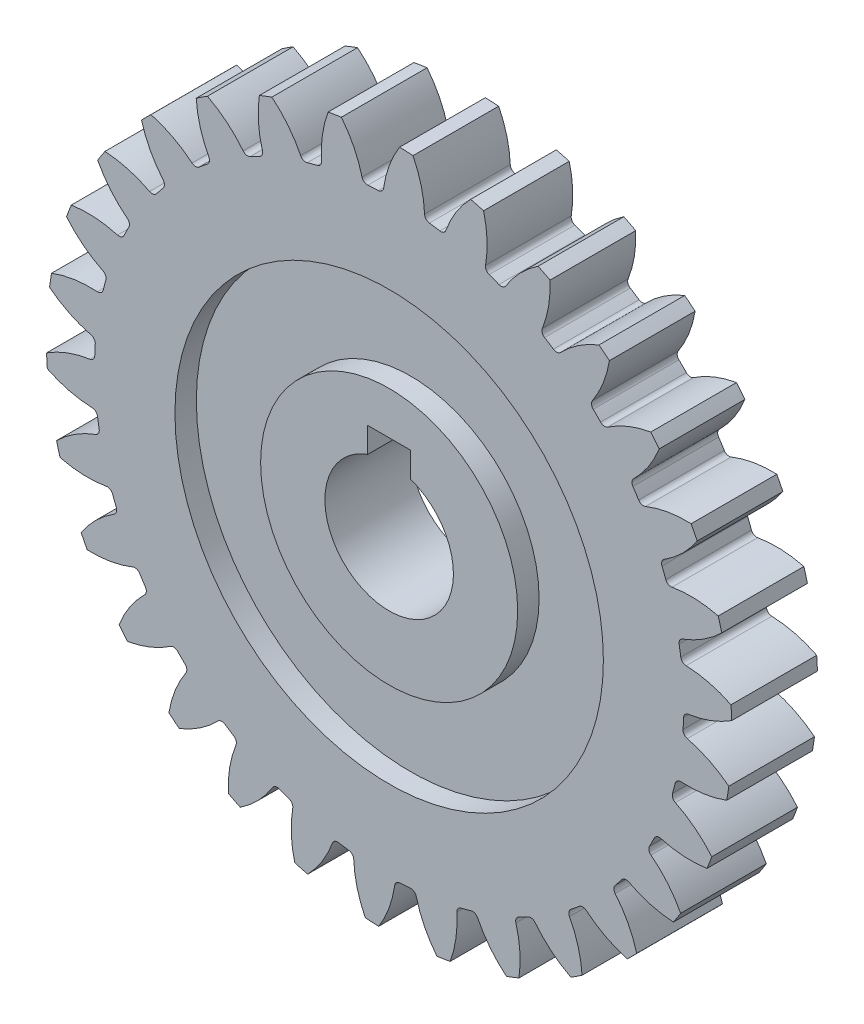
from build123d import *

# Parameters (mm, degrees)
SKETCH1_R           = 80
BOSS_EXTRUDE2_DEPTH = 10
CUT_EXTRUDE1_DEPTH  = 20
SKETCH3_R           = 50
CUT_EXTRUDE2_DEPTH  = 5
SKETCH4_R           = 15
CUT_EXTRUDE3_DEPTH  = 16
SKETCH5_R           = 30
SKETCH5_R_2         = 15
BOSS_EXTRUDE3_DEPTH = 5
SKETCH6_W           = 10
SKETCH6_H           = 10
CUT_EXTRUDE4_DEPTH  = 21


with BuildPart() as part:
    # Sketch1 → Boss-Extrude2 (new body, symmetric)
    with BuildSketch(Plane.XY):
        Circle(SKETCH1_R)
    extrude(amount=BOSS_EXTRUDE2_DEPTH, both=True)

    # Sketch2 → Cut-Extrude1 (cut)
    with BuildSketch(Plane.XY.offset(10)):
        with BuildLine():
            ThreePointArc((19.012601921, 77.707920885), (12.331914738, 79.043809871), (5.561789996, 79.806431395))
            ThreePointArc((5.561789996, 79.806431395), (7.470498978, 74.717944098), (8.264356437, 69.34154537))
            ThreePointArc((8.264356437, 69.34154537), (8.600794132, 68.520294229), (9.385815062, 68.106306431))
            ThreePointArc((9.385815062, 68.106306431), (10.597739228, 67.928274108), (11.806299123, 67.728677833))
            ThreePointArc((11.806299123, 67.728677833), (12.680118941, 67.883863802), (13.250731596, 68.56360269))
            ThreePointArc((13.250731596, 68.56360269), (15.64458276, 73.442675302), (19.012601921, 77.707920885))
        make_face()
        with BuildLine():
            ThreePointArc((-4.979384841, 68.569440909), (-3.756929125, 68.647272222), (-2.533280764, 68.703311336))
            ThreePointArc((-2.533280764, 68.703311336), (-1.710820983, 69.036783475), (-1.294003245, 69.820305479))
            ThreePointArc((-1.294003245, 69.820305479), (0.033120291, 75.090468292), (2.440745731, 79.962758583))
            ThreePointArc((2.440745731, 79.962758583), (-4.371699345, 79.880462222), (-11.152438549, 79.218830554))
            ThreePointArc((-11.152438549, 79.218830554), (-8.22748344, 74.638381825), (-6.333157521, 69.544522555))
            ThreePointArc((-6.333157521, 69.544522555), (-5.833324084, 68.811167052), (-4.979384841, 68.569440909))
        make_face()
        with BuildLine():
            ThreePointArc((-15.782183935, 68.025525884), (-15.579789694, 73.456447493), (-14.237782758, 78.722840028))
            ThreePointArc((-14.237782758, 78.722840028), (-20.884249189, 77.225955066), (-27.379252014, 75.168986684))
            ThreePointArc((-27.379252014, 75.168986684), (-23.565885352, 71.296764112), (-20.653882106, 66.708070393))
            ThreePointArc((-20.653882106, 66.708070393), (-20.012498046, 66.094661683), (-19.126961734, 66.035761787))
            ThreePointArc((-19.126961734, 66.035761787), (-17.947401647, 66.366055134), (-16.762144126, 66.675280459))
            ThreePointArc((-16.762144126, 66.675280459), (-16.026989821, 67.172464435), (-15.782183935, 68.025525884))
        make_face()
        with BuildLine():
            ThreePointArc((-29.580607456, 63.257704386), (-30.511788109, 68.612027456), (-30.294051821, 74.04235561))
            ThreePointArc((-30.294051821, 74.04235561), (-36.484057131, 71.196303101), (-42.409460786, 67.833897395))
            ThreePointArc((-42.409460786, 67.833897395), (-37.874344993, 64.839135687), (-34.071932934, 60.956155454))
            ThreePointArc((-34.071932934, 60.956155454), (-33.317029813, 60.48950244), (-32.438598617, 60.616003001))
            ThreePointArc((-32.438598617, 60.616003001), (-31.353486597, 61.184322978), (-30.258421356, 61.733219882))
            ThreePointArc((-30.258421356, 61.733219882), (-29.642702297, 62.37238637), (-29.580607456, 63.257704386))
        make_face()
        with BuildLine():
            ThreePointArc((-42.086216488, 55.725217661), (-44.110274972, 60.768932582), (-45.026325452, 66.125864957))
            ThreePointArc((-45.026325452, 66.125864957), (-50.489336705, 62.055031054), (-55.586172618, 57.534141287))
            ThreePointArc((-55.586172618, 57.534141287), (-50.527514016, 55.5477259), (-46.000876798, 52.540164022))
            ThreePointArc((-46.000876798, 52.540164022), (-45.165447504, 52.24066168), (-44.332513083, 52.547034015))
            ThreePointArc((-44.332513083, 52.547034015), (-43.389273731, 53.328542312), (-42.432260377, 54.093121368))
            ThreePointArc((-42.432260377, 54.093121368), (-41.962886442, 54.846335725), (-42.086216488, 55.725217661))
        make_face()
        with BuildLine():
            ThreePointArc((-52.752455906, 45.757271526), (-55.780931154, 50.269943752), (-57.790732601, 55.319356698))
            ThreePointArc((-57.790732601, 55.319356698), (-62.287989991, 50.201656376), (-66.333501975, 44.719867125))
            ThreePointArc((-66.333501975, 44.719867125), (-60.972388218, 43.828613943), (-55.919361609, 41.827915306))
            ThreePointArc((-55.919361609, 41.827915306), (-55.039918411, 41.708653326), (-54.288883996, 42.181507494))
            ThreePointArc((-54.288883996, 42.181507494), (-53.528741398, 43.142048448), (-52.751606006, 44.088893882))
            ThreePointArc((-52.751606006, 44.088893882), (-52.449091089, 44.923237027), (-52.752455906, 45.757271526))
        make_face()
        with BuildLine():
            ThreePointArc((-61.113159868, 33.789513057), (-65.013692977, 37.573917159), (-68.029407424, 42.095127099))
            ThreePointArc((-68.029407424, 42.095127099), (-71.364359223, 36.154228421), (-74.181738993, 29.95112018))
            ThreePointArc((-74.181738993, 29.95112018), (-68.752476478, 30.193981244), (-63.393901987, 29.287585978))
            ThreePointArc((-63.393901987, 29.287585978), (-62.508880773, 29.353776681), (-61.872570171, 29.972446687))
            ThreePointArc((-61.872570171, 29.972446687), (-61.328746207, 31.070040049), (-60.765453323, 32.157770172))
            ThreePointArc((-60.765453323, 32.157770172), (-60.643018776, 33.036777305), (-61.113159868, 33.789513057))
        make_face()
        with BuildLine():
            ThreePointArc((-66.802925489, 20.344990727), (-71.405044448, 23.235730086), (-75.294870702, 27.031138452))
            ThreePointArc((-75.294870702, 27.031138452), (-77.321763513, 20.526687196), (-78.787878052, 13.873365562))
            ThreePointArc((-78.787878052, 13.873365562), (-73.527751604, 15.239726678), (-68.097824651, 15.467248606))
            ThreePointArc((-68.097824651, 15.467248606), (-67.245905095, 15.71599914), (-66.752128133, 16.453446135))
            ThreePointArc((-66.752128133, 16.453446135), (-66.448390519, 17.640121809), (-66.123558745, 18.821197594))
            ThreePointArc((-66.123558745, 18.821197594), (-66.186555546, 19.706451886), (-66.802925489, 20.344990727))
        make_face()
        with BuildLine():
            ThreePointArc((-69.573082711, 6.011294676), (-74.675652837, 7.882030111), (-79.269586825, 10.785759344))
            ThreePointArc((-79.269586825, 10.785759344), (-79.899835707, 4.002031243), (-79.950608775, -2.810721704))
            ThreePointArc((-79.950608775, -2.810721704), (-75.08951116, -0.380577072), (-69.825545607, 0.97091825))
            ThreePointArc((-69.825545607, 0.97091825), (-69.043960682, 1.391357023), (-68.714297783, 2.215351035))
            ThreePointArc((-68.714297783, 2.215351035), (-68.66392131, 3.439245599), (-68.591747354, 4.662048368))
            ThreePointArc((-68.591747354, 4.662048368), (-68.83742224, 5.514859959), (-69.573082711, 6.011294676))
        make_face()
        with BuildLine():
            ThreePointArc((-69.30256237, -8.585123797), (-74.682576863, -7.816152402), (-79.779841626, -5.931009203))
            ThreePointArc((-79.779841626, -5.931009203), (-78.985901678, -12.69753268), (-77.619114249, -19.371966943))
            ThreePointArc((-77.619114249, -19.371966943), (-73.369498759, -15.984247778), (-68.501555161, -13.567845893))
            ThreePointArc((-68.501555161, -13.567845893), (-67.824463877, -12.994094072), (-67.673322892, -12.119565536))
            ThreePointArc((-67.673322892, -12.119565536), (-67.878509254, -10.911942147), (-68.062147463, -9.700854742))
            ThreePointArc((-68.062147463, -9.700854742), (-68.479763263, -8.917757812), (-69.30256237, -8.585123797))
        make_face()
        with BuildLine():
            ThreePointArc((-66.003187502, -22.806331164), (-71.425513913, -23.172731549), (-76.803334522, -22.388564187))
            ThreePointArc((-76.803334522, -22.388564187), (-74.619904729, -28.842153495), (-71.895291972, -35.08656427))
            ThreePointArc((-71.895291972, -35.08656427), (-68.442887197, -30.889330155), (-64.183718047, -27.513630064))
            ThreePointArc((-64.183718047, -27.513630064), (-63.640712543, -26.811640904), (-63.674699058, -25.924798936))
            ThreePointArc((-63.674699058, -25.924798936), (-64.126480627, -24.786225659), (-64.55790513, -23.639783951))
            ThreePointArc((-64.55790513, -23.639783951), (-65.12921003, -22.960626775), (-66.003187502, -22.806331164))
        make_face()
        with BuildLine():
            ThreePointArc((-59.819156622, -36.030792423), (-65.046813268, -37.516551133), (-70.470153156, -37.867631484))
            ThreePointArc((-70.470153156, -37.867631484), (-66.992659878, -43.726233802), (-63.029300444, -49.267710375))
            ThreePointArc((-63.029300444, -49.267710375), (-60.524993038, -44.444400581), (-57.060744467, -40.256936577))
            ThreePointArc((-57.060744467, -40.256936577), (-56.675556689, -39.457390371), (-56.89318533, -38.596994223))
            ThreePointArc((-56.89318533, -38.596994223), (-57.571817083, -37.577232173), (-58.232172559, -36.545541165))
            ThreePointArc((-58.232172559, -36.545541165), (-58.932197793, -36.00000617), (-59.819156622, -36.030792423))
        make_face()
        with BuildLine():
            ThreePointArc((-51.020741554, -47.680535158), (-55.825254754, -50.220717407), (-61.057087943, -51.691701577))
            ThreePointArc((-61.057087943, -51.691701577), (-56.437514324, -56.69926787), (-51.408626038, -61.295621123))
            ThreePointArc((-51.408626038, -61.295621123), (-49.961866252, -56.057037434), (-47.443942545, -51.240821787))
            ThreePointArc((-47.443942545, -51.240821787), (-47.233407049, -50.378662542), (-47.625166399, -49.582315652))
            ThreePointArc((-47.625166399, -49.582315652), (-48.500988872, -48.725933326), (-49.361414619, -47.854082865))
            ThreePointArc((-49.361414619, -47.854082865), (-50.159565725, -47.466012549), (-51.020741554, -47.680535158))
        make_face()
        with BuildLine():
            ThreePointArc((-39.992475255, -57.246409709), (-44.163864728, -60.729997345), (-48.975535004, -63.256596266))
            ThreePointArc((-48.975535004, -63.256596266), (-43.415778576, -67.194271859), (-37.541147989, -70.644619099))
            ThreePointArc((-37.541147989, -70.644619099), (-37.215166168, -65.219712759), (-35.753612673, -59.985237204))
            ThreePointArc((-35.753612673, -59.985237204), (-35.726930869, -59.098145417), (-36.275699166, -58.400651966))
            ThreePointArc((-36.275699166, -58.400651966), (-37.310434714, -57.745077379), (-38.333325997, -57.071171514))
            ThreePointArc((-38.333325997, -57.071171514), (-39.194719942, -56.857526411), (-39.992475255, -57.246409709))
        make_face()
        with BuildLine():
            ThreePointArc((-27.216345882, -64.310341458), (-30.572301891, -68.585084984), (-34.753516173, -72.056874159))
            ThreePointArc((-34.753516173, -72.056874159), (-28.496564973, -74.752563734), (-22.03294163, -76.90610823))
            ThreePointArc((-22.03294163, -76.90610823), (-22.841984744, -71.531973678), (-22.500678363, -66.108009914))
            ThreePointArc((-22.500678363, -66.108009914), (-22.659016373, -65.234755752), (-23.340809809, -64.666599551))
            ThreePointArc((-23.340809809, -64.666599551), (-24.489235523, -64.240484459), (-25.629887086, -63.79397611))
            ThreePointArc((-25.629887086, -63.79397611), (-26.516876821, -63.764093537), (-27.216345882, -64.310341458))
        make_face()
        with BuildLine():
            ThreePointArc((-13.250731596, -68.56360269), (-15.64458276, -73.442675302), (-19.012601921, -77.707920885))
            ThreePointArc((-19.012601921, -77.707920885), (-12.331914738, -79.043809871), (-5.561789996, -79.806431395))
            ThreePointArc((-5.561789996, -79.806431395), (-7.470498978, -74.717944098), (-8.264356437, -69.34154537))
            ThreePointArc((-8.264356437, -69.34154537), (-8.600794132, -68.520294229), (-9.385815062, -68.106306431))
            ThreePointArc((-9.385815062, -68.106306431), (-10.597739228, -67.928274108), (-11.806299123, -67.728677833))
            ThreePointArc((-11.806299123, -67.728677833), (-12.680118941, -67.883863802), (-13.250731596, -68.56360269))
        make_face()
        with BuildLine():
            ThreePointArc((1.294003245, -69.820305479), (-0.033120291, -75.090468292), (-2.440745731, -79.962758583))
            ThreePointArc((-2.440745731, -79.962758583), (4.371699345, -79.880462222), (11.152438549, -79.218830554))
            ThreePointArc((11.152438549, -79.218830554), (8.22748344, -74.638381825), (6.333157521, -69.544522555))
            ThreePointArc((6.333157521, -69.544522555), (5.833324084, -68.811167052), (4.979384841, -68.569440909))
            ThreePointArc((4.979384841, -68.569440909), (3.756929125, -68.647272222), (2.533280764, -68.703311336))
            ThreePointArc((2.533280764, -68.703311336), (1.710820983, -69.036783475), (1.294003245, -69.820305479))
        make_face()
        with BuildLine():
            ThreePointArc((14.237782758, -78.722840028), (20.884249189, -77.225955066), (27.379252014, -75.168986684))
            ThreePointArc((27.379252014, -75.168986684), (23.565885352, -71.296764112), (20.653882106, -66.708070393))
            ThreePointArc((20.653882106, -66.708070393), (20.012498046, -66.094661683), (19.126961734, -66.035761787))
            ThreePointArc((19.126961734, -66.035761787), (17.947401647, -66.366055134), (16.762144126, -66.675280459))
            ThreePointArc((16.762144126, -66.675280459), (16.026989821, -67.172464435), (15.782183935, -68.025525884))
            ThreePointArc((15.782183935, -68.025525884), (15.579789694, -73.456447493), (14.237782758, -78.722840028))
        make_face()
        with BuildLine():
            ThreePointArc((30.294051821, -74.04235561), (36.484057131, -71.196303101), (42.409460786, -67.833897395))
            ThreePointArc((42.409460786, -67.833897395), (37.874344993, -64.839135687), (34.071932934, -60.956155454))
            ThreePointArc((34.071932934, -60.956155454), (33.317029813, -60.48950244), (32.438598617, -60.616003001))
            ThreePointArc((32.438598617, -60.616003001), (31.353486597, -61.184322978), (30.258421356, -61.733219882))
            ThreePointArc((30.258421356, -61.733219882), (29.642702297, -62.37238637), (29.580607456, -63.257704386))
            ThreePointArc((29.580607456, -63.257704386), (30.511788109, -68.612027456), (30.294051821, -74.04235561))
        make_face()
        with BuildLine():
            ThreePointArc((45.026325452, -66.125864957), (50.489336705, -62.055031054), (55.586172618, -57.534141287))
            ThreePointArc((55.586172618, -57.534141287), (50.527514016, -55.5477259), (46.000876798, -52.540164022))
            ThreePointArc((46.000876798, -52.540164022), (45.165447504, -52.24066168), (44.332513083, -52.547034015))
            ThreePointArc((44.332513083, -52.547034015), (43.389273731, -53.328542312), (42.432260377, -54.093121368))
            ThreePointArc((42.432260377, -54.093121368), (41.962886442, -54.846335725), (42.086216488, -55.725217661))
            ThreePointArc((42.086216488, -55.725217661), (44.110274972, -60.768932582), (45.026325452, -66.125864957))
        make_face()
        with BuildLine():
            ThreePointArc((57.790732601, -55.319356698), (62.287989991, -50.201656376), (66.333501975, -44.719867125))
            ThreePointArc((66.333501975, -44.719867125), (60.972388218, -43.828613943), (55.919361609, -41.827915306))
            ThreePointArc((55.919361609, -41.827915306), (55.039918411, -41.708653326), (54.288883996, -42.181507494))
            ThreePointArc((54.288883996, -42.181507494), (53.528741398, -43.142048448), (52.751606006, -44.088893882))
            ThreePointArc((52.751606006, -44.088893882), (52.449091089, -44.923237027), (52.752455906, -45.757271526))
            ThreePointArc((52.752455906, -45.757271526), (55.780931154, -50.269943752), (57.790732601, -55.319356698))
        make_face()
        with BuildLine():
            ThreePointArc((68.029407424, -42.095127099), (71.364359223, -36.154228421), (74.181738993, -29.95112018))
            ThreePointArc((74.181738993, -29.95112018), (68.752476478, -30.193981244), (63.393901987, -29.287585978))
            ThreePointArc((63.393901987, -29.287585978), (62.508880773, -29.353776681), (61.872570171, -29.972446687))
            ThreePointArc((61.872570171, -29.972446687), (61.328746207, -31.070040049), (60.765453323, -32.157770171))
            ThreePointArc((60.765453323, -32.157770171), (60.643018776, -33.036777305), (61.113159868, -33.789513057))
            ThreePointArc((61.113159868, -33.789513057), (65.013692977, -37.573917159), (68.029407424, -42.095127099))
        make_face()
        with BuildLine():
            ThreePointArc((75.294870702, -27.031138452), (77.321763513, -20.526687196), (78.787878052, -13.873365562))
            ThreePointArc((78.787878052, -13.873365562), (73.527751604, -15.239726678), (68.097824651, -15.467248606))
            ThreePointArc((68.097824651, -15.467248606), (67.245905095, -15.71599914), (66.752128133, -16.453446135))
            ThreePointArc((66.752128133, -16.453446135), (66.448390519, -17.640121809), (66.123558745, -18.821197594))
            ThreePointArc((66.123558745, -18.821197594), (66.186555546, -19.706451886), (66.802925489, -20.344990727))
            ThreePointArc((66.802925489, -20.344990727), (71.405044448, -23.235730086), (75.294870702, -27.031138452))
        make_face()
        with BuildLine():
            ThreePointArc((80, 0), (79.987651241, 1.405577816), (79.950608775, 2.810721704))
            ThreePointArc((79.950608775, 2.810721704), (75.089511161, 0.380577072), (69.825545607, -0.97091825))
            ThreePointArc((69.825545607, -0.97091825), (69.043960682, -1.391357023), (68.714297783, -2.215351035))
            ThreePointArc((68.714297783, -2.215351035), (68.66392131, -3.439245599), (68.591747354, -4.662048368))
            ThreePointArc((68.591747354, -4.662048368), (68.83742224, -5.514859959), (69.573082711, -6.011294676))
            ThreePointArc((69.573082711, -6.011294676), (74.675652837, -7.882030111), (79.269586825, -10.785759344))
            ThreePointArc((79.269586825, -10.785759344), (79.817187829, -5.405231448), (80, 0))
        make_face()
        with BuildLine():
            ThreePointArc((79.779841626, 5.931009203), (78.985901678, 12.69753268), (77.619114249, 19.371966943))
            ThreePointArc((77.619114249, 19.371966943), (73.369498759, 15.984247778), (68.501555161, 13.567845893))
            ThreePointArc((68.501555161, 13.567845893), (67.824463877, 12.994094072), (67.673322892, 12.119565536))
            ThreePointArc((67.673322892, 12.119565536), (67.878509254, 10.911942147), (68.062147463, 9.700854742))
            ThreePointArc((68.062147463, 9.700854742), (68.479763263, 8.917757812), (69.30256237, 8.585123797))
            ThreePointArc((69.30256237, 8.585123797), (74.682576863, 7.816152402), (79.779841626, 5.931009203))
        make_face()
        with BuildLine():
            ThreePointArc((76.803334522, 22.388564187), (74.619904729, 28.842153495), (71.895291972, 35.08656427))
            ThreePointArc((71.895291972, 35.08656427), (68.442887197, 30.889330155), (64.183718047, 27.513630064))
            ThreePointArc((64.183718047, 27.513630064), (63.640712543, 26.811640904), (63.674699058, 25.924798936))
            ThreePointArc((63.674699058, 25.924798936), (64.126480627, 24.786225659), (64.55790513, 23.639783951))
            ThreePointArc((64.55790513, 23.639783951), (65.12921003, 22.960626775), (66.003187502, 22.806331164))
            ThreePointArc((66.003187502, 22.806331164), (71.425513913, 23.172731549), (76.803334522, 22.388564187))
        make_face()
        with BuildLine():
            ThreePointArc((70.470153156, 37.867631484), (66.992659878, 43.726233802), (63.029300444, 49.267710375))
            ThreePointArc((63.029300444, 49.267710375), (60.524993038, 44.444400581), (57.060744467, 40.256936577))
            ThreePointArc((57.060744467, 40.256936577), (56.675556689, 39.457390371), (56.89318533, 38.596994223))
            ThreePointArc((56.89318533, 38.596994223), (57.571817083, 37.577232173), (58.232172559, 36.545541165))
            ThreePointArc((58.232172559, 36.545541165), (58.932197793, 36.00000617), (59.819156622, 36.030792423))
            ThreePointArc((59.819156622, 36.030792423), (65.046813268, 37.516551133), (70.470153156, 37.867631484))
        make_face()
        with BuildLine():
            ThreePointArc((61.057087943, 51.691701577), (56.437514324, 56.69926787), (51.408626038, 61.295621123))
            ThreePointArc((51.408626038, 61.295621123), (49.961866252, 56.057037434), (47.443942545, 51.240821787))
            ThreePointArc((47.443942545, 51.240821787), (47.233407049, 50.378662542), (47.625166399, 49.582315652))
            ThreePointArc((47.625166399, 49.582315652), (48.500988872, 48.725933326), (49.361414619, 47.854082865))
            ThreePointArc((49.361414619, 47.854082865), (50.159565725, 47.466012549), (51.020741554, 47.680535158))
            ThreePointArc((51.020741554, 47.680535158), (55.825254754, 50.220717407), (61.057087943, 51.691701577))
        make_face()
        with BuildLine():
            ThreePointArc((48.975535004, 63.256596266), (43.415778576, 67.194271859), (37.541147989, 70.644619099))
            ThreePointArc((37.541147989, 70.644619099), (37.215166168, 65.219712759), (35.753612673, 59.985237204))
            ThreePointArc((35.753612673, 59.985237204), (35.726930869, 59.098145417), (36.275699166, 58.400651966))
            ThreePointArc((36.275699166, 58.400651966), (37.310434714, 57.745077379), (38.333325997, 57.071171514))
            ThreePointArc((38.333325997, 57.071171514), (39.194719942, 56.857526411), (39.992475255, 57.246409709))
            ThreePointArc((39.992475255, 57.246409709), (44.163864728, 60.729997345), (48.975535004, 63.256596266))
        make_face()
        with BuildLine():
            ThreePointArc((34.753516173, 72.056874159), (28.496564973, 74.752563734), (22.03294163, 76.90610823))
            ThreePointArc((22.03294163, 76.90610823), (22.841984744, 71.531973678), (22.500678363, 66.108009914))
            ThreePointArc((22.500678363, 66.108009914), (22.659016373, 65.234755752), (23.340809809, 64.666599551))
            ThreePointArc((23.340809809, 64.666599551), (24.489235523, 64.240484459), (25.629887086, 63.79397611))
            ThreePointArc((25.629887086, 63.79397611), (26.516876821, 63.764093537), (27.216345882, 64.310341458))
            ThreePointArc((27.216345882, 64.310341458), (30.572301891, 68.585084984), (34.753516173, 72.056874159))
        make_face()
    extrude(amount=-CUT_EXTRUDE1_DEPTH, mode=Mode.SUBTRACT)

    # Sketch3 → Cut-Extrude2 (cut)
    with BuildSketch(Plane.XY.offset(10)):
        Circle(SKETCH3_R)
    extrude(amount=-CUT_EXTRUDE2_DEPTH, mode=Mode.SUBTRACT)

    # Sketch4 → Cut-Extrude3 (cut, through all)
    with BuildSketch(Plane.XY.offset(5)):
        Circle(SKETCH4_R)
    extrude(amount=-CUT_EXTRUDE3_DEPTH, mode=Mode.SUBTRACT)

    # Sketch5 → Boss-Extrude3 (add)
    with BuildSketch(Plane.XY.offset(5)):
        Circle(SKETCH5_R)
        Circle(SKETCH5_R_2, mode=Mode.SUBTRACT)
    extrude(amount=BOSS_EXTRUDE3_DEPTH)

    # Sketch6 → Cut-Extrude4 (cut, through all)
    with BuildSketch(Plane.XY.offset(10)):
        with Locations((0, 15)):
            Rectangle(SKETCH6_W, SKETCH6_H)
    extrude(amount=-CUT_EXTRUDE4_DEPTH, mode=Mode.SUBTRACT)


solid = part.part
